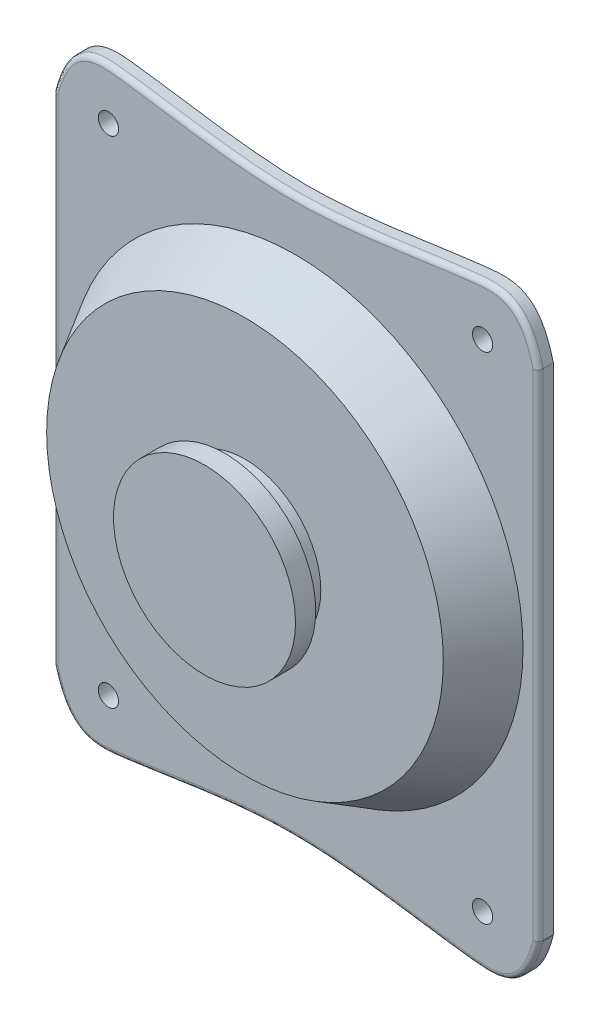
from build123d import *

# Parameters (mm, degrees)
BOSS_EXTRUDE1_DEPTH = 1.5
SKETCH2_R           = 22.5
BOSS_EXTRUDE4_DEPTH = 5
BOSS_EXTRUDE4_TAPER = 30
SKETCH3_R           = 7.5
BOSS_EXTRUDE5_DEPTH = 2
SKETCH4_R           = 9
BOSS_EXTRUDE7_DEPTH = 2
FILLET4_R           = 0.5
SKETCH5_R           = 1
CUT_EXTRUDE1_DEPTH  = 2


with BuildPart() as part:
    # Sketch1 → Boss-Extrude1 (new body)
    with BuildSketch(Plane.XY):
        with BuildLine():
            Line((-24, 24.5), (-24, -24.5))
            add(Edge.make_bspline(
                [(-24, -24.5), (-22.605605166, -29.952275609), (-14.106399585, -29.149385859), (-0.230857067, -26.321865732), (15.046005443, -29.389446711), (22.664200818, -29.845368103), (24, -24.5)],
                knots=[0, 0, 0, 0, 0.159886605, 0.492954102, 0.826021599, 1, 1, 1, 1], degree=3))
            Line((24, -24.5), (24, 24.5))
            add(Edge.make_bspline(
                [(-24, 24.5), (-22.605605166, 29.952275609), (-14.106399585, 29.149385859), (-0.230857067, 26.321865732), (15.046005443, 29.389446711), (22.664200818, 29.845368103), (24, 24.5)],
                knots=[0, 0, 0, 0, 0.159886605, 0.492954102, 0.826021599, 1, 1, 1, 1], degree=3))
        make_face()
    extrude(amount=BOSS_EXTRUDE1_DEPTH)

    # Sketch2 → Boss-Extrude4 (add)
    with BuildSketch(Plane.XY.offset(1.5)):
        Circle(SKETCH2_R)
    extrude(amount=BOSS_EXTRUDE4_DEPTH, taper=BOSS_EXTRUDE4_TAPER)

    # Sketch3 → Boss-Extrude5 (add)
    with BuildSketch(Plane.XY.offset(6.5)):
        Circle(SKETCH3_R)
    extrude(amount=BOSS_EXTRUDE5_DEPTH)

    # Sketch4 → Boss-Extrude7 (add)
    with BuildSketch(Plane.XY.offset(8.5)):
        Circle(SKETCH4_R)
    extrude(amount=BOSS_EXTRUDE7_DEPTH)

    # Fillet4
    fillet4_edges = [part.edges().sort_by_distance(p)[0] for p in [
        (-24, 0, 1.5),
        (0.007188855, 27.500047519, 1.5),
        (0.007188855, -27.500047519, 1.5),
        (24, 0, 1.5),
    ]]
    fillet(fillet4_edges, radius=FILLET4_R)

    # Sketch5 → Cut-Extrude1 (cut)
    with BuildSketch(Plane.XY.offset(1.5)):
        with Locations((18.5, -24.5)):
            Circle(SKETCH5_R)
        with Locations((-18.5, -24.5)):
            Circle(SKETCH5_R)
        with Locations((18.5, 24.5)):
            Circle(SKETCH5_R)
        with Locations((-18.5, 24.5)):
            Circle(SKETCH5_R)
    extrude(amount=-CUT_EXTRUDE1_DEPTH, mode=Mode.SUBTRACT)


solid = part.part
